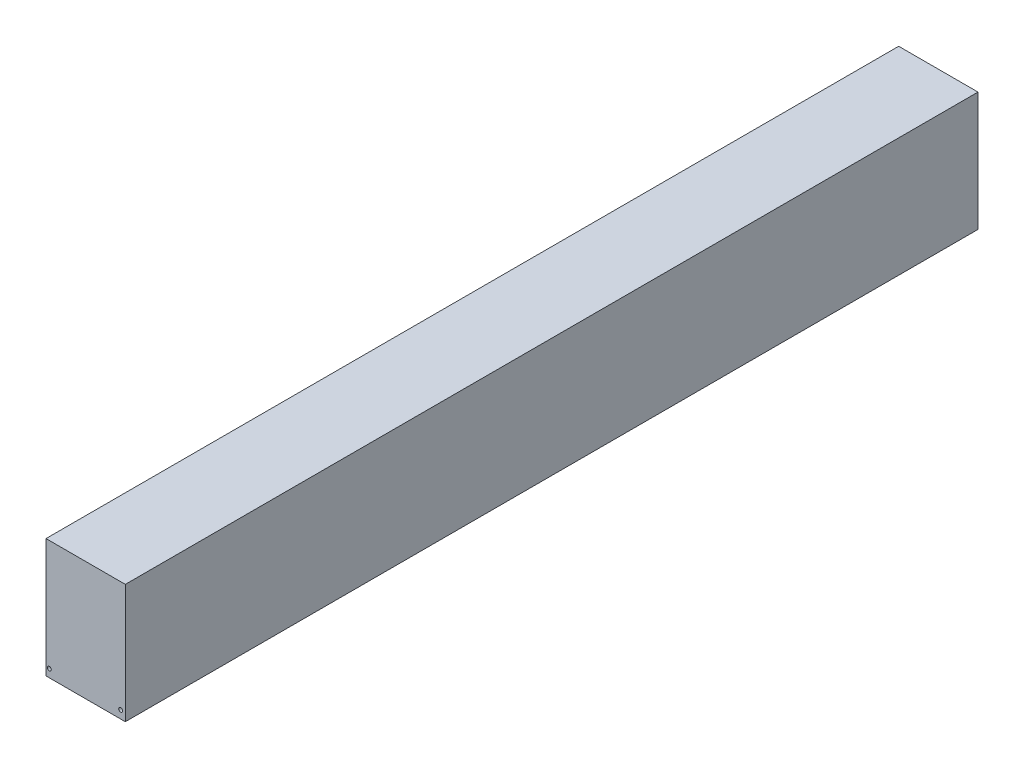
from build123d import *

# Parameters (mm, degrees)
SKETCH1_W                = 100
SKETCH1_H                = 150
BOSS_EXTRUDE1_DEPTH      = 1075
SKETCH3_R                = 1.7
CUT_EXTRUDE1_DEPTH       = 3.5
LPATTERN1_COUNT          = 29
LPATTERN1_PITCH          = 37.95
LPATTERN2_COUNT          = 4
LPATTERN2_PITCH          = 30.425
MIRROR1_COPY_1_SKETCH_R  = 1.7
MIRROR1_COPY_1_DEPTH     = 3.5
MIRROR1_COPY_2_SKETCH_R  = 1.7
MIRROR1_COPY_2_DEPTH     = 3.5
MIRROR1_COPY_3_SKETCH_R  = 1.7
MIRROR1_COPY_3_DEPTH     = 3.5
MIRROR1_COPY_4_SKETCH_R  = 1.7
MIRROR1_COPY_4_DEPTH     = 3.5
MIRROR1_COPY_5_SKETCH_R  = 1.7
MIRROR1_COPY_5_DEPTH     = 3.5
MIRROR1_COPY_6_SKETCH_R  = 1.7
MIRROR1_COPY_6_DEPTH     = 3.5
MIRROR1_COPY_7_SKETCH_R  = 1.7
MIRROR1_COPY_7_DEPTH     = 3.5
MIRROR1_COPY_8_SKETCH_R  = 1.7
MIRROR1_COPY_8_DEPTH     = 3.5
MIRROR1_COPY_9_SKETCH_R  = 1.7
MIRROR1_COPY_9_DEPTH     = 3.5
MIRROR1_COPY_10_SKETCH_R = 1.7
MIRROR1_COPY_10_DEPTH    = 3.5
MIRROR1_COPY_11_SKETCH_R = 1.7
MIRROR1_COPY_11_DEPTH    = 3.5
MIRROR1_COPY_12_SKETCH_R = 1.7
MIRROR1_COPY_12_DEPTH    = 3.5
MIRROR1_COPY_13_SKETCH_R = 1.7
MIRROR1_COPY_13_DEPTH    = 3.5
MIRROR1_COPY_14_SKETCH_R = 1.7
MIRROR1_COPY_14_DEPTH    = 3.5
MIRROR1_COPY_15_SKETCH_R = 1.7
MIRROR1_COPY_15_DEPTH    = 3.5
MIRROR1_COPY_16_SKETCH_R = 1.7
MIRROR1_COPY_16_DEPTH    = 3.5
MIRROR1_COPY_17_SKETCH_R = 1.7
MIRROR1_COPY_17_DEPTH    = 3.5
MIRROR1_COPY_18_SKETCH_R = 1.7
MIRROR1_COPY_18_DEPTH    = 3.5
MIRROR1_COPY_19_SKETCH_R = 1.7
MIRROR1_COPY_19_DEPTH    = 3.5
MIRROR1_COPY_20_SKETCH_R = 1.7
MIRROR1_COPY_20_DEPTH    = 3.5
MIRROR1_COPY_21_SKETCH_R = 1.7
MIRROR1_COPY_21_DEPTH    = 3.5
MIRROR1_COPY_22_SKETCH_R = 1.7
MIRROR1_COPY_22_DEPTH    = 3.5
MIRROR1_COPY_23_SKETCH_R = 1.7
MIRROR1_COPY_23_DEPTH    = 3.5
MIRROR1_COPY_24_SKETCH_R = 1.7
MIRROR1_COPY_24_DEPTH    = 3.5
MIRROR1_COPY_25_SKETCH_R = 1.7
MIRROR1_COPY_25_DEPTH    = 3.5
MIRROR1_COPY_26_SKETCH_R = 1.7
MIRROR1_COPY_26_DEPTH    = 3.5
MIRROR1_COPY_27_SKETCH_R = 1.7
MIRROR1_COPY_27_DEPTH    = 3.5
MIRROR1_COPY_28_SKETCH_R = 1.7
MIRROR1_COPY_28_DEPTH    = 3.5
MIRROR2_COPY_1_SKETCH_R  = 1.7
MIRROR2_COPY_1_DEPTH     = 3.5
MIRROR2_COPY_2_SKETCH_R  = 1.7
MIRROR2_COPY_2_DEPTH     = 3.5
MIRROR2_COPY_3_SKETCH_R  = 1.7
MIRROR2_COPY_3_DEPTH     = 3.5
SKETCH4_R                = 2.5
CUT_EXTRUDE2_DEPTH       = 7.5


with BuildPart() as part:
    # Sketch1 → Boss-Extrude1 (new body)
    with BuildSketch(Plane.XY):
        Rectangle(SKETCH1_W, SKETCH1_H)
    extrude(amount=BOSS_EXTRUDE1_DEPTH)

    # Sketch3 → Cut-Extrude1 (cut)
    with BuildSketch(Plane.XZ.offset(75)):
        with Locations((45.75, 1068.75)):
            Circle(SKETCH3_R)
    cut_extrude1 = extrude(amount=-CUT_EXTRUDE1_DEPTH, mode=Mode.SUBTRACT)

    # LPattern1: Cut-Extrude1 ×29
    with Locations(*[(0, 0, -i * LPATTERN1_PITCH) for i in range(1, LPATTERN1_COUNT)]):
        add(cut_extrude1, mode=Mode.SUBTRACT)

    # LPattern2: Cut-Extrude1 ×4
    with Locations(*[(-i * LPATTERN2_PITCH, 0, 0) for i in range(1, LPATTERN2_COUNT)]):
        add(cut_extrude1, mode=Mode.SUBTRACT)

    # Mirror1: Cut-Extrude1 across plane
    add(cut_extrude1.mirror(Plane.ZY), mode=Mode.SUBTRACT)

    # Mirror1 copy 1 sketch → Mirror1 copy 1 (cut)
    with BuildSketch(Plane(origin=(0, -75, -37.95), x_dir=(-1, 0, 0), z_dir=(0, -1, 0))):
        with Locations((45.75, -1068.75)):
            Circle(MIRROR1_COPY_1_SKETCH_R)
    extrude(amount=-MIRROR1_COPY_1_DEPTH, mode=Mode.SUBTRACT)

    # Mirror1 copy 2 sketch → Mirror1 copy 2 (cut)
    with BuildSketch(Plane(origin=(0, -75, -75.9), x_dir=(-1, 0, 0), z_dir=(0, -1, 0))):
        with Locations((45.75, -1068.75)):
            Circle(MIRROR1_COPY_2_SKETCH_R)
    extrude(amount=-MIRROR1_COPY_2_DEPTH, mode=Mode.SUBTRACT)

    # Mirror1 copy 3 sketch → Mirror1 copy 3 (cut)
    with BuildSketch(Plane(origin=(0, -75, -113.85), x_dir=(-1, 0, 0), z_dir=(0, -1, 0))):
        with Locations((45.75, -1068.75)):
            Circle(MIRROR1_COPY_3_SKETCH_R)
    extrude(amount=-MIRROR1_COPY_3_DEPTH, mode=Mode.SUBTRACT)

    # Mirror1 copy 4 sketch → Mirror1 copy 4 (cut)
    with BuildSketch(Plane(origin=(0, -75, -151.8), x_dir=(-1, 0, 0), z_dir=(0, -1, 0))):
        with Locations((45.75, -1068.75)):
            Circle(MIRROR1_COPY_4_SKETCH_R)
    extrude(amount=-MIRROR1_COPY_4_DEPTH, mode=Mode.SUBTRACT)

    # Mirror1 copy 5 sketch → Mirror1 copy 5 (cut)
    with BuildSketch(Plane(origin=(0, -75, -189.75), x_dir=(-1, 0, 0), z_dir=(0, -1, 0))):
        with Locations((45.75, -1068.75)):
            Circle(MIRROR1_COPY_5_SKETCH_R)
    extrude(amount=-MIRROR1_COPY_5_DEPTH, mode=Mode.SUBTRACT)

    # Mirror1 copy 6 sketch → Mirror1 copy 6 (cut)
    with BuildSketch(Plane(origin=(0, -75, -227.7), x_dir=(-1, 0, 0), z_dir=(0, -1, 0))):
        with Locations((45.75, -1068.75)):
            Circle(MIRROR1_COPY_6_SKETCH_R)
    extrude(amount=-MIRROR1_COPY_6_DEPTH, mode=Mode.SUBTRACT)

    # Mirror1 copy 7 sketch → Mirror1 copy 7 (cut)
    with BuildSketch(Plane(origin=(0, -75, -265.65), x_dir=(-1, 0, 0), z_dir=(0, -1, 0))):
        with Locations((45.75, -1068.75)):
            Circle(MIRROR1_COPY_7_SKETCH_R)
    extrude(amount=-MIRROR1_COPY_7_DEPTH, mode=Mode.SUBTRACT)

    # Mirror1 copy 8 sketch → Mirror1 copy 8 (cut)
    with BuildSketch(Plane(origin=(0, -75, -303.6), x_dir=(-1, 0, 0), z_dir=(0, -1, 0))):
        with Locations((45.75, -1068.75)):
            Circle(MIRROR1_COPY_8_SKETCH_R)
    extrude(amount=-MIRROR1_COPY_8_DEPTH, mode=Mode.SUBTRACT)

    # Mirror1 copy 9 sketch → Mirror1 copy 9 (cut)
    with BuildSketch(Plane(origin=(0, -75, -341.55), x_dir=(-1, 0, 0), z_dir=(0, -1, 0))):
        with Locations((45.75, -1068.75)):
            Circle(MIRROR1_COPY_9_SKETCH_R)
    extrude(amount=-MIRROR1_COPY_9_DEPTH, mode=Mode.SUBTRACT)

    # Mirror1 copy 10 sketch → Mirror1 copy 10 (cut)
    with BuildSketch(Plane(origin=(0, -75, -379.5), x_dir=(-1, 0, 0), z_dir=(0, -1, 0))):
        with Locations((45.75, -1068.75)):
            Circle(MIRROR1_COPY_10_SKETCH_R)
    extrude(amount=-MIRROR1_COPY_10_DEPTH, mode=Mode.SUBTRACT)

    # Mirror1 copy 11 sketch → Mirror1 copy 11 (cut)
    with BuildSketch(Plane(origin=(0, -75, -417.45), x_dir=(-1, 0, 0), z_dir=(0, -1, 0))):
        with Locations((45.75, -1068.75)):
            Circle(MIRROR1_COPY_11_SKETCH_R)
    extrude(amount=-MIRROR1_COPY_11_DEPTH, mode=Mode.SUBTRACT)

    # Mirror1 copy 12 sketch → Mirror1 copy 12 (cut)
    with BuildSketch(Plane(origin=(0, -75, -455.4), x_dir=(-1, 0, 0), z_dir=(0, -1, 0))):
        with Locations((45.75, -1068.75)):
            Circle(MIRROR1_COPY_12_SKETCH_R)
    extrude(amount=-MIRROR1_COPY_12_DEPTH, mode=Mode.SUBTRACT)

    # Mirror1 copy 13 sketch → Mirror1 copy 13 (cut)
    with BuildSketch(Plane(origin=(0, -75, -493.35), x_dir=(-1, 0, 0), z_dir=(0, -1, 0))):
        with Locations((45.75, -1068.75)):
            Circle(MIRROR1_COPY_13_SKETCH_R)
    extrude(amount=-MIRROR1_COPY_13_DEPTH, mode=Mode.SUBTRACT)

    # Mirror1 copy 14 sketch → Mirror1 copy 14 (cut)
    with BuildSketch(Plane(origin=(0, -75, -531.3), x_dir=(-1, 0, 0), z_dir=(0, -1, 0))):
        with Locations((45.75, -1068.75)):
            Circle(MIRROR1_COPY_14_SKETCH_R)
    extrude(amount=-MIRROR1_COPY_14_DEPTH, mode=Mode.SUBTRACT)

    # Mirror1 copy 15 sketch → Mirror1 copy 15 (cut)
    with BuildSketch(Plane(origin=(0, -75, -569.25), x_dir=(-1, 0, 0), z_dir=(0, -1, 0))):
        with Locations((45.75, -1068.75)):
            Circle(MIRROR1_COPY_15_SKETCH_R)
    extrude(amount=-MIRROR1_COPY_15_DEPTH, mode=Mode.SUBTRACT)

    # Mirror1 copy 16 sketch → Mirror1 copy 16 (cut)
    with BuildSketch(Plane(origin=(0, -75, -607.2), x_dir=(-1, 0, 0), z_dir=(0, -1, 0))):
        with Locations((45.75, -1068.75)):
            Circle(MIRROR1_COPY_16_SKETCH_R)
    extrude(amount=-MIRROR1_COPY_16_DEPTH, mode=Mode.SUBTRACT)

    # Mirror1 copy 17 sketch → Mirror1 copy 17 (cut)
    with BuildSketch(Plane(origin=(0, -75, -645.15), x_dir=(-1, 0, 0), z_dir=(0, -1, 0))):
        with Locations((45.75, -1068.75)):
            Circle(MIRROR1_COPY_17_SKETCH_R)
    extrude(amount=-MIRROR1_COPY_17_DEPTH, mode=Mode.SUBTRACT)

    # Mirror1 copy 18 sketch → Mirror1 copy 18 (cut)
    with BuildSketch(Plane(origin=(0, -75, -683.1), x_dir=(-1, 0, 0), z_dir=(0, -1, 0))):
        with Locations((45.75, -1068.75)):
            Circle(MIRROR1_COPY_18_SKETCH_R)
    extrude(amount=-MIRROR1_COPY_18_DEPTH, mode=Mode.SUBTRACT)

    # Mirror1 copy 19 sketch → Mirror1 copy 19 (cut)
    with BuildSketch(Plane(origin=(0, -75, -721.05), x_dir=(-1, 0, 0), z_dir=(0, -1, 0))):
        with Locations((45.75, -1068.75)):
            Circle(MIRROR1_COPY_19_SKETCH_R)
    extrude(amount=-MIRROR1_COPY_19_DEPTH, mode=Mode.SUBTRACT)

    # Mirror1 copy 20 sketch → Mirror1 copy 20 (cut)
    with BuildSketch(Plane(origin=(0, -75, -759), x_dir=(-1, 0, 0), z_dir=(0, -1, 0))):
        with Locations((45.75, -1068.75)):
            Circle(MIRROR1_COPY_20_SKETCH_R)
    extrude(amount=-MIRROR1_COPY_20_DEPTH, mode=Mode.SUBTRACT)

    # Mirror1 copy 21 sketch → Mirror1 copy 21 (cut)
    with BuildSketch(Plane(origin=(0, -75, -796.95), x_dir=(-1, 0, 0), z_dir=(0, -1, 0))):
        with Locations((45.75, -1068.75)):
            Circle(MIRROR1_COPY_21_SKETCH_R)
    extrude(amount=-MIRROR1_COPY_21_DEPTH, mode=Mode.SUBTRACT)

    # Mirror1 copy 22 sketch → Mirror1 copy 22 (cut)
    with BuildSketch(Plane(origin=(0, -75, -834.9), x_dir=(-1, 0, 0), z_dir=(0, -1, 0))):
        with Locations((45.75, -1068.75)):
            Circle(MIRROR1_COPY_22_SKETCH_R)
    extrude(amount=-MIRROR1_COPY_22_DEPTH, mode=Mode.SUBTRACT)

    # Mirror1 copy 23 sketch → Mirror1 copy 23 (cut)
    with BuildSketch(Plane(origin=(0, -75, -872.85), x_dir=(-1, 0, 0), z_dir=(0, -1, 0))):
        with Locations((45.75, -1068.75)):
            Circle(MIRROR1_COPY_23_SKETCH_R)
    extrude(amount=-MIRROR1_COPY_23_DEPTH, mode=Mode.SUBTRACT)

    # Mirror1 copy 24 sketch → Mirror1 copy 24 (cut)
    with BuildSketch(Plane(origin=(0, -75, -910.8), x_dir=(-1, 0, 0), z_dir=(0, -1, 0))):
        with Locations((45.75, -1068.75)):
            Circle(MIRROR1_COPY_24_SKETCH_R)
    extrude(amount=-MIRROR1_COPY_24_DEPTH, mode=Mode.SUBTRACT)

    # Mirror1 copy 25 sketch → Mirror1 copy 25 (cut)
    with BuildSketch(Plane(origin=(0, -75, -948.75), x_dir=(-1, 0, 0), z_dir=(0, -1, 0))):
        with Locations((45.75, -1068.75)):
            Circle(MIRROR1_COPY_25_SKETCH_R)
    extrude(amount=-MIRROR1_COPY_25_DEPTH, mode=Mode.SUBTRACT)

    # Mirror1 copy 26 sketch → Mirror1 copy 26 (cut)
    with BuildSketch(Plane(origin=(0, -75, -986.7), x_dir=(-1, 0, 0), z_dir=(0, -1, 0))):
        with Locations((45.75, -1068.75)):
            Circle(MIRROR1_COPY_26_SKETCH_R)
    extrude(amount=-MIRROR1_COPY_26_DEPTH, mode=Mode.SUBTRACT)

    # Mirror1 copy 27 sketch → Mirror1 copy 27 (cut)
    with BuildSketch(Plane(origin=(0, -75, -1024.65), x_dir=(-1, 0, 0), z_dir=(0, -1, 0))):
        with Locations((45.75, -1068.75)):
            Circle(MIRROR1_COPY_27_SKETCH_R)
    extrude(amount=-MIRROR1_COPY_27_DEPTH, mode=Mode.SUBTRACT)

    # Mirror1 copy 28 sketch → Mirror1 copy 28 (cut)
    with BuildSketch(Plane(origin=(0, -75, -1062.6), x_dir=(-1, 0, 0), z_dir=(0, -1, 0))):
        with Locations((45.75, -1068.75)):
            Circle(MIRROR1_COPY_28_SKETCH_R)
    extrude(amount=-MIRROR1_COPY_28_DEPTH, mode=Mode.SUBTRACT)

    # Mirror2: Cut-Extrude1 across plane
    add(cut_extrude1.mirror(Plane(origin=(0, 0, 537.5), x_dir=(1, 0, 0), z_dir=(0, 0, -1))), mode=Mode.SUBTRACT)

    # Mirror2 copy 1 sketch → Mirror2 copy 1 (cut)
    with BuildSketch(Plane(origin=(-30.425, -75, 1075), x_dir=(1, 0, 0), z_dir=(0, -1, 0))):
        with Locations((45.75, -1068.75)):
            Circle(MIRROR2_COPY_1_SKETCH_R)
    extrude(amount=-MIRROR2_COPY_1_DEPTH, mode=Mode.SUBTRACT)

    # Mirror2 copy 2 sketch → Mirror2 copy 2 (cut)
    with BuildSketch(Plane(origin=(-60.85, -75, 1075), x_dir=(1, 0, 0), z_dir=(0, -1, 0))):
        with Locations((45.75, -1068.75)):
            Circle(MIRROR2_COPY_2_SKETCH_R)
    extrude(amount=-MIRROR2_COPY_2_DEPTH, mode=Mode.SUBTRACT)

    # Mirror2 copy 3 sketch → Mirror2 copy 3 (cut)
    with BuildSketch(Plane(origin=(-91.275, -75, 1075), x_dir=(1, 0, 0), z_dir=(0, -1, 0))):
        with Locations((45.75, -1068.75)):
            Circle(MIRROR2_COPY_3_SKETCH_R)
    extrude(amount=-MIRROR2_COPY_3_DEPTH, mode=Mode.SUBTRACT)

    # Sketch4 → Cut-Extrude2 (cut)
    with BuildSketch(Plane(origin=(0, 0, 0), x_dir=(-1, 0, 0), z_dir=(0, 0, -1))):
        with Locations((-44.15, -65)):
            Circle(SKETCH4_R)
        with Locations((45.85, -65)):
            Circle(SKETCH4_R)
    cut_extrude2 = extrude(amount=-CUT_EXTRUDE2_DEPTH, mode=Mode.SUBTRACT)

    # Mirror3: Cut-Extrude2 across plane
    add(cut_extrude2.mirror(Plane(origin=(0, 0, 537.5), x_dir=(1, 0, 0), z_dir=(0, 0, -1))), mode=Mode.SUBTRACT)


solid = part.part
